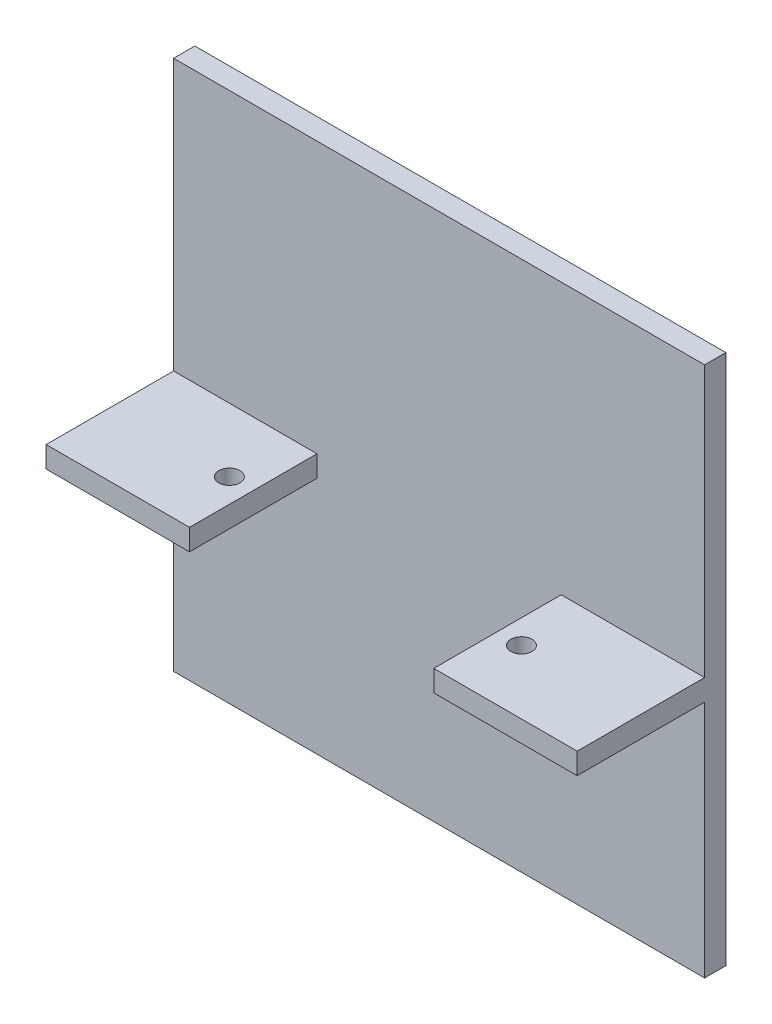
from build123d import *

# Parameters (mm, degrees)
SKETCH_1_W      = 50
SKETCH_1_H      = 50
EXTRUDE_1_DEPTH = 2
EXTRUDE_START   = -22.5
SKETCH_3_W      = 13.5
SKETCH_3_H      = 12
SKETCH_3_R      = 1
EXTRUDE_3_DEPTH = 2


with BuildPart() as part:
    # 草图1 → 凸台-拉伸1 (new body)
    with BuildSketch(Plane.XY):
        Rectangle(SKETCH_1_W, SKETCH_1_H)
    extrude(amount=EXTRUDE_1_DEPTH)

    # 草图3 → 凸台-拉伸3 (add)
    with BuildSketch(Plane.XZ.offset(25).offset(EXTRUDE_START)):
        with Locations((-18.25, 8)):
            Rectangle(SKETCH_3_W, SKETCH_3_H)
        with Locations((-13.75, 8)):
            Circle(SKETCH_3_R, mode=Mode.SUBTRACT)
    extrude_3 = extrude(amount=-EXTRUDE_3_DEPTH)

    # 镜向1: 凸台-拉伸3 across plane
    add(extrude_3.mirror(Plane(origin=(0, 0, 0), x_dir=(0, 0, 1), z_dir=(1, 0, 0))))


solid = part.part
